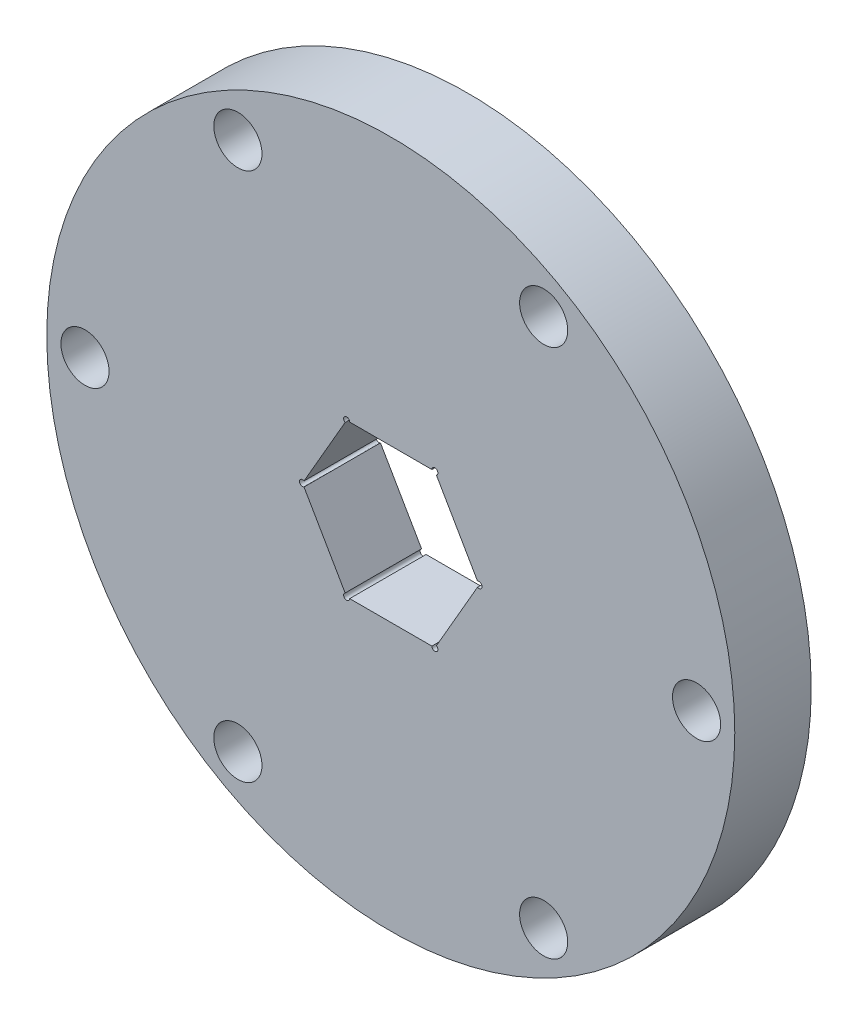
from build123d import *

# Parameters (mm, degrees)
SKETCH1_R           = 28.575
BOSS_EXTRUDE1_DEPTH = 6.35
SKETCH2_R           = 14.2875
BOSS_EXTRUDE2_DEPTH = 12.7
CUT_EXTRUDE1_DEPTH  = 20.05
SKETCH4_R           = 2
CUT_EXTRUDE2_DEPTH  = 7.35
FILLET1_R           = 1
SKETCH5_R           = 14.2875
CUT_EXTRUDE4_DEPTH  = 12.7
SKETCH7_R           = 0.25
CUT_EXTRUDE5_DEPTH  = 12.7


with BuildPart() as part:
    # Sketch1 → Boss-Extrude1 (new body)
    with BuildSketch(Plane.XY):
        Circle(SKETCH1_R)
    extrude(amount=BOSS_EXTRUDE1_DEPTH)

    # Sketch2 → Boss-Extrude2 (add)
    with BuildSketch(Plane.XY.offset(6.35)):
        Circle(SKETCH2_R)
    extrude(amount=BOSS_EXTRUDE2_DEPTH)

    # Sketch3 → Cut-Extrude1 (cut, through all)
    with BuildSketch(Plane.XY.offset(19.05)):
        Polygon((7.332348419, 0), (3.666174209, 6.35), (-3.666174209, 6.35), (-7.332348419, 0), (-3.666174209, -6.35), (3.666174209, -6.35), align=None)
    extrude(amount=-CUT_EXTRUDE1_DEPTH, mode=Mode.SUBTRACT)

    # Sketch4 → Cut-Extrude2 (cut, through all)
    with BuildSketch(Plane.XY.offset(6.35)):
        with Locations((25.4, 0)):
            Circle(SKETCH4_R)
        with Locations((12.7, -21.997045256)):
            Circle(SKETCH4_R)
        with Locations((-12.7, -21.997045256)):
            Circle(SKETCH4_R)
        with Locations((-25.4, 0)):
            Circle(SKETCH4_R)
        with Locations((-12.7, 21.997045256)):
            Circle(SKETCH4_R)
        with Locations((12.7, 21.997045256)):
            Circle(SKETCH4_R)
    extrude(amount=-CUT_EXTRUDE2_DEPTH, mode=Mode.SUBTRACT)

    # Fillet1
    fillet1_edges = [part.edges().sort_by_distance(p)[0] for p in [
        (5.499261314, -3.175, 19.05),
        (5.499261314, 3.175, 19.05),
        (0, 6.35, 19.05),
        (-5.499261314, 3.175, 19.05),
        (-5.499261314, -3.175, 19.05),
        (0, -6.35, 19.05),
    ]]
    fillet(fillet1_edges, radius=FILLET1_R)

    # Sketch5 → Cut-Extrude4 (cut)
    with BuildSketch(Plane.XY.offset(19.05)):
        Circle(SKETCH5_R)
    extrude(amount=-CUT_EXTRUDE4_DEPTH, mode=Mode.SUBTRACT)

    # Sketch7 → Cut-Extrude5 (cut)
    with BuildSketch(Plane.XY.offset(6.35)):
        with Locations((-3.666174209, 6.35)):
            Circle(SKETCH7_R)
        with Locations((3.666174209, 6.35)):
            Circle(SKETCH7_R)
        with Locations((7.332348419, 0)):
            Circle(SKETCH7_R)
        with Locations((3.666174209, -6.35)):
            Circle(SKETCH7_R)
        with Locations((-3.666174209, -6.35)):
            Circle(SKETCH7_R)
        with Locations((-7.332348419, 0)):
            Circle(SKETCH7_R)
    extrude(amount=-CUT_EXTRUDE5_DEPTH, mode=Mode.SUBTRACT)


solid = part.part
